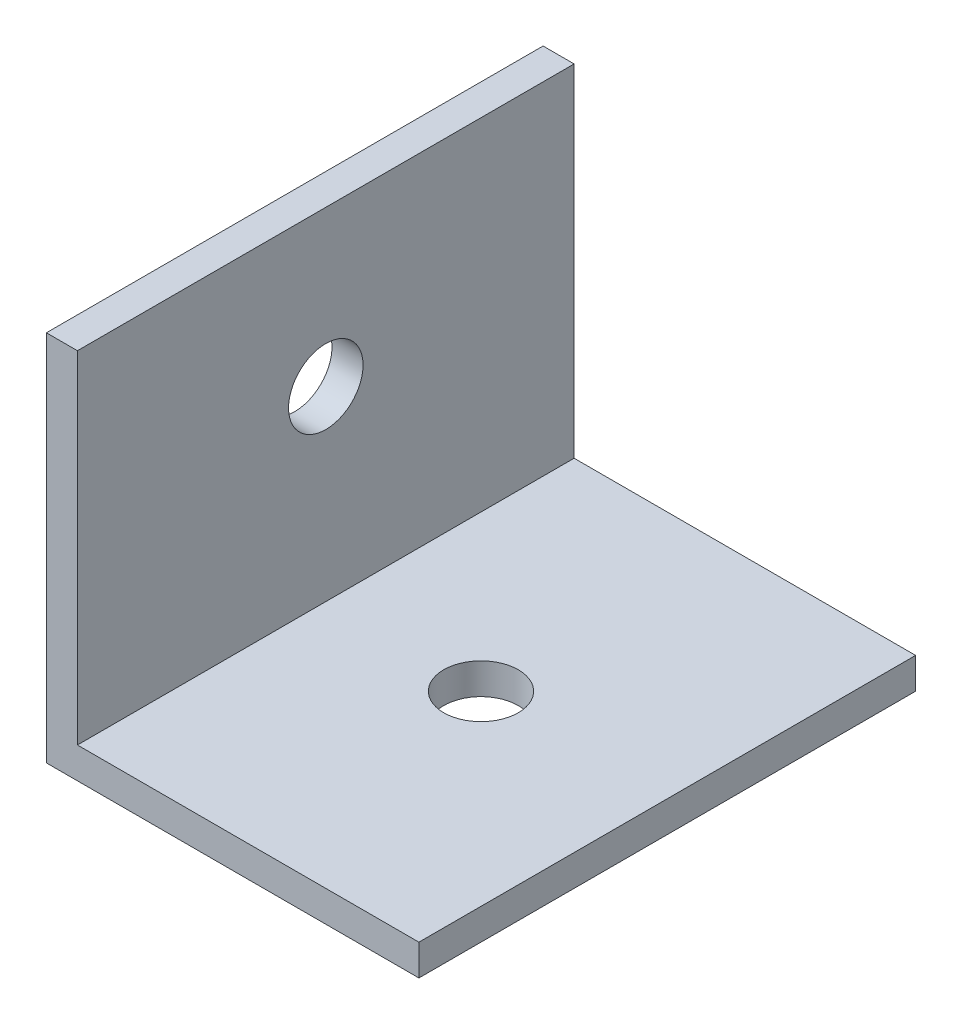
from build123d import *

# Parameters (mm, degrees)
EXTRUDE_THIN1_DEPTH = 40
SKETCH2_R           = 6
CUT_EXTRUDE1_DEPTH  = 61
SKETCH3_R           = 6
CUT_EXTRUDE2_DEPTH  = 61


with BuildPart() as part:
    # Sketch1 → Extrude-Thin1 (new body, symmetric)
    with BuildSketch(Plane.XY):
        Polygon((60, 0), (0, 0), (0, 60), (5, 60), (5, 5), (60, 5), align=None)
    extrude(amount=EXTRUDE_THIN1_DEPTH, both=True)

    # Sketch2 → Cut-Extrude1 (cut, through all)
    with BuildSketch(Plane.XZ):
        with Locations((30, 0)):
            Circle(SKETCH2_R)
    extrude(amount=-CUT_EXTRUDE1_DEPTH, mode=Mode.SUBTRACT)

    # Sketch3 → Cut-Extrude2 (cut, through all)
    with BuildSketch(Plane(origin=(0, 0, 0), x_dir=(0, -1, 0), z_dir=(-1, 0, 0))):
        with Locations((-35, 0)):
            Circle(SKETCH3_R)
    extrude(amount=-CUT_EXTRUDE2_DEPTH, mode=Mode.SUBTRACT)


solid = part.part
